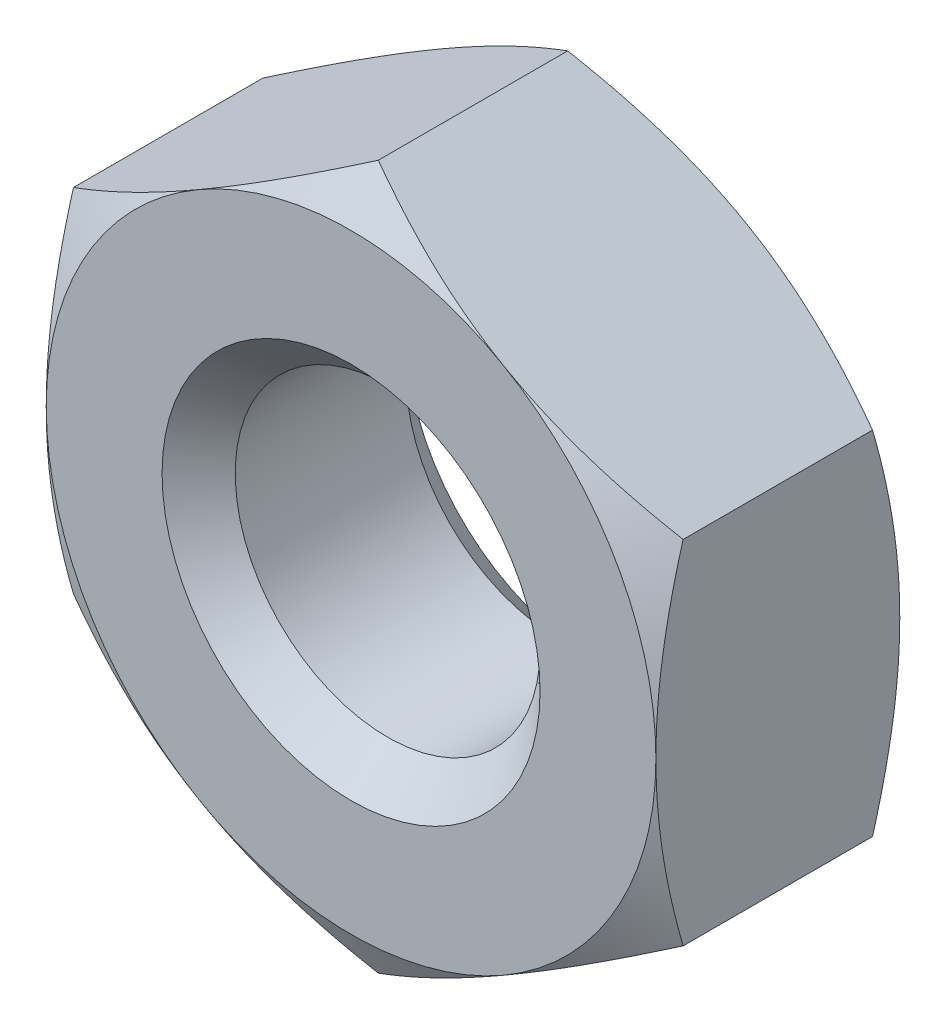
from build123d import *

# Parameters (mm, degrees)
SKETCH1_R           = 3.5
SKETCH1_R_2         = 1.25
BOSS_EXTRUDE1_DEPTH = 2
CHAMFER1_SIZE       = 1
CHAMFER1_SIZE2      = 0.577350269
CHAMFER2_SIZE       = 1
CHAMFER2_SIZE2      = 0.577350269
SKETCH1_3_R         = 3.5
CUT_EXTRUDE1_DEPTH  = 6.338539126
CHAMFER3_SIZE       = 0.3


with BuildPart() as part:
    # Sketch1 → Boss-Extrude1 (new body)
    with BuildSketch(Plane.XY):
        Circle(SKETCH1_R)
        Circle(SKETCH1_R_2, mode=Mode.SUBTRACT)
    extrude(amount=BOSS_EXTRUDE1_DEPTH)

    # Chamfer1
    chamfer1_edges = [part.edges().sort_by_distance(p)[0] for p in [
        (-3.5, 0, 2),
    ]]
    chamfer1_side = [part.faces().sort_by_distance(p)[0] for p in [
        (-3.401005051, 0, 2),
    ]]
    chamfer(chamfer1_edges, length=CHAMFER1_SIZE, length2=CHAMFER1_SIZE2, reference=chamfer1_side[0])

    # Chamfer2
    chamfer2_edges = [part.edges().sort_by_distance(p)[0] for p in [
        (-3.5, 0, 0),
    ]]
    chamfer2_side = [part.faces().sort_by_distance(p)[0] for p in [
        (-3.401005051, 0, 0),
    ]]
    chamfer(chamfer2_edges, length=CHAMFER2_SIZE, length2=CHAMFER2_SIZE2, reference=chamfer2_side[0])

    # Sketch1_3 → Cut-Extrude1 (cut, through all)
    with BuildSketch(Plane.XY):
        Circle(SKETCH1_3_R)
        Polygon((-2.5, 1.443375673), (0, 2.886751346), (2.5, 1.443375673), (2.5, -1.443375673), (0, -2.886751346), (-2.5, -1.443375673), align=None, mode=Mode.SUBTRACT)
    extrude(amount=CUT_EXTRUDE1_DEPTH, mode=Mode.SUBTRACT)

    # Chamfer3
    chamfer3_edges = [part.edges().sort_by_distance(p)[0] for p in [
        (-1.25, 0, 0),
        (-1.25, 0, 2),
    ]]
    chamfer(chamfer3_edges, length=CHAMFER3_SIZE)


solid = part.part
